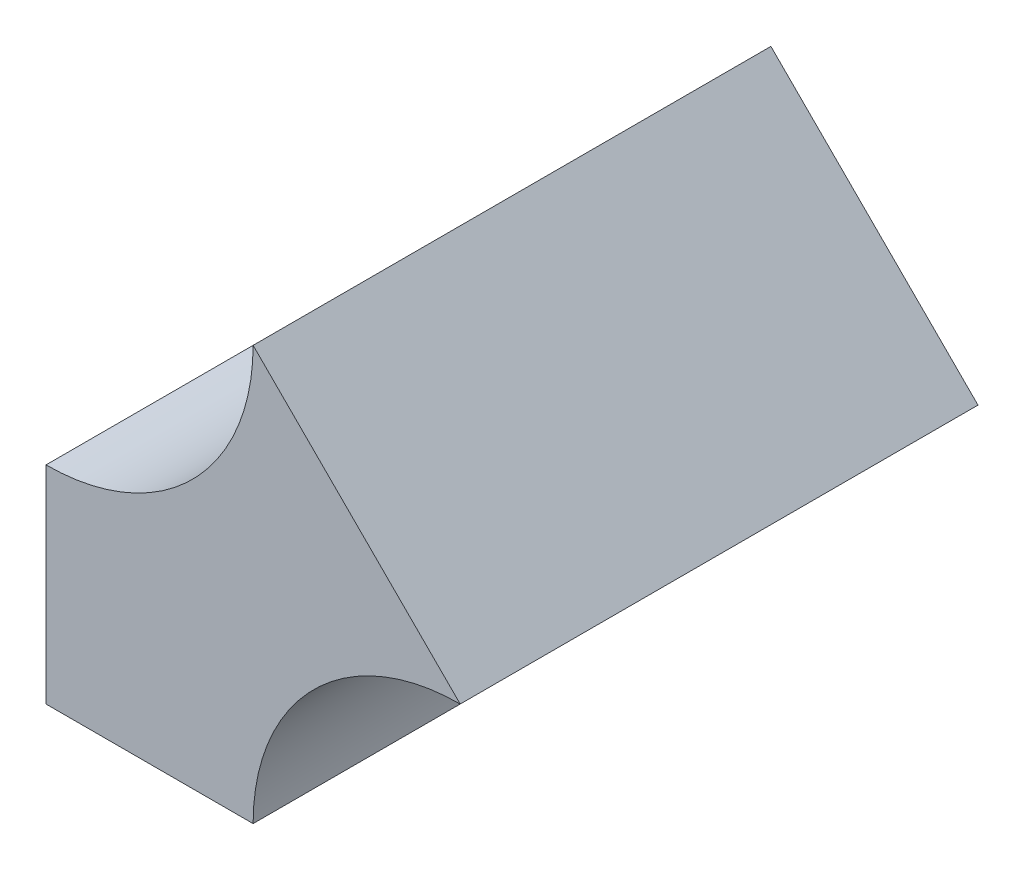
from build123d import *

# Parameters (mm, degrees)
BOSS_EXTRUDE1_DEPTH = 25


with BuildPart() as part:
    # Sketch1 → Boss-Extrude1 (new body)
    with BuildSketch(Plane.XY):
        with BuildLine():
            Line((-10, 10), (-10, 0))
            Line((-10, 0), (0, 0))
            ThreePointArc((0, 0), (2.928932188, 7.071067812), (10, 10))
            Line((10, 10), (0, 20))
            ThreePointArc((0, 20), (-2.928932188, 12.928932188), (-10, 10))
        make_face()
    extrude(amount=BOSS_EXTRUDE1_DEPTH)


solid = part.part
